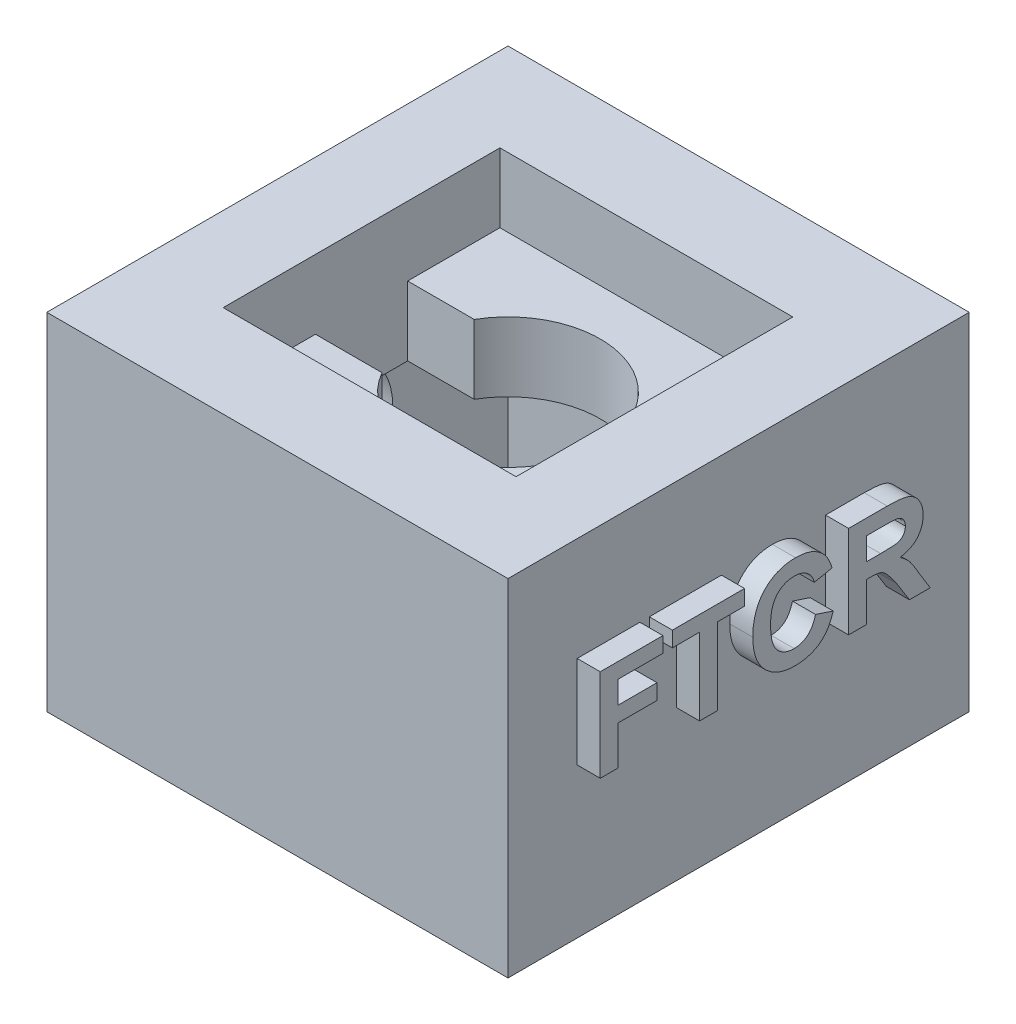
from build123d import *

# Parameters (mm, degrees)
SKETCH6_W           = 20
SKETCH6_H           = 20
BOSS_EXTRUDE3_DEPTH = 15
SKETCH7_W           = 12.7
SKETCH7_H           = 12
CUT_EXTRUDE2_DEPTH  = 3
SKETCH8_W           = 16
SKETCH8_H           = 16
CUT_EXTRUDE3_DEPTH  = 9
SKETCH9_R           = 4
CUT_EXTRUDE4_DEPTH  = 13
SKETCH10_W          = 12.7
SKETCH10_H          = 4
CUT_EXTRUDE5_DEPTH  = 13
SKETCH11_R          = 3
CUT_EXTRUDE6_DEPTH  = 3
BOSS_EXTRUDE4_DEPTH = 1


with BuildPart() as part:
    # Sketch6 → Boss-Extrude3 (new body)
    with BuildSketch(Plane(origin=(0, 0, 0), x_dir=(1, 0, 0), z_dir=(0, 1, 0))):
        Rectangle(SKETCH6_W, SKETCH6_H)
    extrude(amount=BOSS_EXTRUDE3_DEPTH)

    # Sketch7 → Cut-Extrude2 (cut)
    with BuildSketch(Plane(origin=(0, 15, 0), x_dir=(1, 0, 0), z_dir=(0, 1, 0))):
        Rectangle(SKETCH7_W, SKETCH7_H)
    extrude(amount=-CUT_EXTRUDE2_DEPTH, mode=Mode.SUBTRACT)

    # Sketch8 → Cut-Extrude3 (cut)
    with BuildSketch(Plane.XZ):
        Rectangle(SKETCH8_W, SKETCH8_H)
    extrude(amount=-CUT_EXTRUDE3_DEPTH, mode=Mode.SUBTRACT)

    # Sketch9 → Cut-Extrude4 (cut, through all)
    with BuildSketch(Plane(origin=(0, 12, 0), x_dir=(1, 0, 0), z_dir=(0, 1, 0))):
        Circle(SKETCH9_R)
    extrude(amount=-CUT_EXTRUDE4_DEPTH, mode=Mode.SUBTRACT)

    # Sketch10 → Cut-Extrude5 (cut, through all)
    with BuildSketch(Plane(origin=(0, 12, 0), x_dir=(1, 0, 0), z_dir=(0, 1, 0))):
        Rectangle(SKETCH10_W, SKETCH10_H)
    extrude(amount=-CUT_EXTRUDE5_DEPTH, mode=Mode.SUBTRACT)

    # Sketch11 → Cut-Extrude6 (cut, through all)
    with BuildSketch(Plane(origin=(-8, 0, 0), x_dir=(0, 0, -1), z_dir=(1, 0, 0))):
        with Locations((0, 6)):
            Circle(SKETCH11_R)
    extrude(amount=-CUT_EXTRUDE6_DEPTH, mode=Mode.SUBTRACT)

    # Sketch12 → Boss-Extrude4 (add)
    with BuildSketch(Plane(origin=(10, 0, 0), x_dir=(0, 0, -1), z_dir=(1, 0, 0))):
        Polygon((-7, 6.5), (-7, 10.5), (-4.282051282, 10.5), (-4.282051282, 9.833333333), (-6.230769231, 9.833333333), (-6.230769231, 8.858974359), (-4.538461538, 8.858974359), (-4.538461538, 8.192307692), (-6.230769231, 8.192307692), (-6.230769231, 6.5), align=None)
        Polygon((-2.692307692, 6.5), (-2.692307692, 9.833333333), (-3.871794872, 9.833333333), (-3.871794872, 10.5), (-0.743589744, 10.5), (-0.743589744, 9.833333333), (-1.923076923, 9.833333333), (-1.923076923, 6.5), align=None)
        with BuildLine():
            Line((2.333333333, 7.987179487), (3.102564103, 7.730769231))
            add(Edge.make_bspline(
                [(3.102564103, 7.730769231), (3.086930966, 7.680332707), (3.056316366, 7.581562127), (3.000102828, 7.440000434), (2.93582352, 7.308808759), (2.865790067, 7.18645159), (2.785647227, 7.076089811), (2.699881822, 6.974069408), (2.605943704, 6.882539125), (2.50429639, 6.801303513), (2.395918291, 6.729465094), (2.279550482, 6.668733578), (2.156929586, 6.616427097), (2.026812158, 6.574047819), (1.890061746, 6.540108451), (1.746036707, 6.517691314), (1.595410776, 6.502491754), (1.492561226, 6.500843752), (1.439903846, 6.5)],
                knots=[0, 0, 0, 0, 0.000158372, 0.000310143, 0.000456354, 0.000596395, 0.000732484, 0.000864938, 0.000995832, 0.001125226, 0.001254791, 0.00138526, 0.00151846, 0.001654277, 0.001795369, 0.001940668, 0.002091201, 0.002249127, 0.002249127, 0.002249127, 0.002249127], degree=3))
            add(Edge.make_bspline(
                [(1.439903846, 6.5), (1.37490907, 6.501343951), (1.247062403, 6.503987543), (1.060098762, 6.530598944), (0.881930865, 6.572119076), (0.712303833, 6.629602977), (0.552349902, 6.705740257), (0.400609747, 6.797399672), (0.258187679, 6.906442057), (0.125583338, 7.031029627), (0.005109088, 7.170211291), (-0.099069972, 7.323234951), (-0.188087376, 7.487944876), (-0.260035831, 7.665126422), (-0.316294668, 7.854597653), (-0.355704101, 8.056096597), (-0.380364017, 8.269686724), (-0.383173502, 8.416062825), (-0.384615385, 8.491185897)],
                knots=[0, 0, 0, 0, 0.000194876, 0.000383328, 0.000565247, 0.000743131, 0.000919481, 0.001095654, 0.001274025, 0.001456555, 0.001640634, 0.001825103, 0.002010814, 0.002201277, 0.002397754, 0.002602828, 0.002816524, 0.003041826, 0.003041826, 0.003041826, 0.003041826], degree=3))
            add(Edge.make_bspline(
                [(-0.384615385, 8.491185897), (-0.383180001, 8.570314328), (-0.38037983, 8.724679457), (-0.355673717, 8.94911314), (-0.317318946, 9.160628802), (-0.260965024, 9.357914963), (-0.190073862, 9.542360053), (-0.100948381, 9.712133102), (0.002191496, 9.869497646), (0.122118975, 10.011569389), (0.255327645, 10.137709886), (0.39807721, 10.249252186), (0.551699395, 10.342828179), (0.715353547, 10.419349729), (0.889259153, 10.478565871), (1.073074015, 10.521206141), (1.266948526, 10.54602552), (1.399501491, 10.549505903), (1.467147436, 10.551282051)],
                knots=[0, 0, 0, 0, 0.000237315, 0.000462958, 0.000676534, 0.000881474, 0.001077592, 0.001268258, 0.001455604, 0.001640993, 0.001824625, 0.002005097, 0.002183471, 0.002363062, 0.002546015, 0.002733578, 0.002928278, 0.003131194, 0.003131194, 0.003131194, 0.003131194], degree=3))
            add(Edge.make_bspline(
                [(1.467147436, 10.551282051), (1.526225253, 10.549793443), (1.642055176, 10.54687483), (1.811676336, 10.527045661), (1.972429727, 10.492246794), (2.125184274, 10.445276061), (2.269070412, 10.383287189), (2.404345914, 10.307537426), (2.531475755, 10.218427566), (2.608074101, 10.148822211), (2.646634615, 10.113782051)],
                knots=[0, 0, 0, 0, 0.00017723, 0.000347483, 0.000511402, 0.000670052, 0.000826188, 0.000980443, 0.00113451, 0.001290694, 0.001290694, 0.001290694, 0.001290694], degree=3))
            add(Edge.make_bspline(
                [(2.646634615, 10.113782051), (2.668983783, 10.091485642), (2.714207085, 10.046369096), (2.774592886, 9.970199583), (2.831846127, 9.88820309), (2.885058086, 9.79898086), (2.932546964, 9.701858642), (2.976597971, 9.598327922), (3.017154081, 9.487989626), (3.039707942, 9.411200989), (3.051282051, 9.371794872)],
                knots=[0, 0, 0, 0, 9.4636e-05, 0.000191495, 0.000291077, 0.000394554, 0.000502775, 0.000615143, 0.000732001, 0.000855185, 0.000855185, 0.000855185, 0.000855185], degree=3))
            Line((3.051282051, 9.371794872), (2.282051282, 9.217948718))
            add(Edge.make_bspline(
                [(2.282051282, 9.217948718), (2.275513137, 9.243179532), (2.262634706, 9.292877615), (2.236576953, 9.364291032), (2.206686657, 9.432055987), (2.169640371, 9.494512679), (2.130287637, 9.554439631), (2.083696219, 9.6091759), (2.032841611, 9.660156003), (1.977357464, 9.706850892), (1.917905228, 9.748317024), (1.855629569, 9.785592493), (1.789398602, 9.816020924), (1.720093361, 9.840637453), (1.647989885, 9.861276558), (1.57244623, 9.874026295), (1.494111228, 9.883813973), (1.440738816, 9.884344332), (1.413461538, 9.884615385)],
                knots=[0, 0, 0, 0, 7.8149e-05, 0.000153932, 0.000227807, 0.000299962, 0.000371524, 0.000442621, 0.000515145, 0.000587372, 0.000659842, 0.000732401, 0.000804819, 0.000878069, 0.000952915, 0.001029458, 0.00110768, 0.001189446, 0.001189446, 0.001189446, 0.001189446], degree=3))
            add(Edge.make_bspline(
                [(1.413461538, 9.884615385), (1.376001256, 9.883858858), (1.302889995, 9.882382343), (1.196026684, 9.865920209), (1.094173803, 9.842945596), (0.997742119, 9.807863482), (0.907328808, 9.762993748), (0.821906318, 9.70844957), (0.741943493, 9.644464572), (0.667413306, 9.570280743), (0.600532593, 9.484556804), (0.5417349, 9.387115764), (0.492956944, 9.276851355), (0.453357, 9.154845615), (0.422187333, 9.020808414), (0.399929736, 8.874567842), (0.387620617, 8.716023857), (0.385638745, 8.606324103), (0.384615385, 8.549679487)],
                knots=[0, 0, 0, 0, 0.000112282, 0.000219142, 0.000323705, 0.000425092, 0.000526146, 0.00062595, 0.000728564, 0.000832817, 0.000940693, 0.001053926, 0.00117336, 0.001301575, 0.00143821, 0.001585759, 0.00174493, 0.001914869, 0.001914869, 0.001914869, 0.001914869], degree=3))
            add(Edge.make_bspline(
                [(0.384615385, 8.549679487), (0.385628668, 8.48956389), (0.387581109, 8.373730394), (0.399887617, 8.206651289), (0.422287541, 8.052982713), (0.453042964, 7.912451958), (0.492842466, 7.785145101), (0.541537934, 7.671282443), (0.599427553, 7.57073064), (0.666421258, 7.483556646), (0.740825334, 7.408674453), (0.820624603, 7.344292817), (0.905348265, 7.289246772), (0.995506149, 7.243958435), (1.091441168, 7.209698313), (1.192364876, 7.184852271), (1.298647581, 7.169057247), (1.371471162, 7.167474695), (1.408653846, 7.166666667)],
                knots=[0, 0, 0, 0, 0.000180353, 0.000347512, 0.000502192, 0.000645857, 0.000778647, 0.000901748, 0.001016642, 0.001125784, 0.001230605, 0.001332594, 0.001432832, 0.001533168, 0.001634555, 0.001737749, 0.001844608, 0.00195609, 0.00195609, 0.00195609, 0.00195609], degree=3))
            add(Edge.make_bspline(
                [(1.408653846, 7.166666667), (1.436182549, 7.167353464), (1.490313655, 7.16870395), (1.570323604, 7.177275378), (1.647116838, 7.193632714), (1.721069235, 7.21526233), (1.792468123, 7.242401116), (1.860224437, 7.277214723), (1.925671252, 7.317227793), (1.987450599, 7.364120046), (2.046389734, 7.416765552), (2.100145723, 7.477610637), (2.150008865, 7.54519333), (2.195346572, 7.619965289), (2.23767372, 7.701286492), (2.273685874, 7.790423966), (2.307234422, 7.88593721), (2.324481746, 7.95284262), (2.333333333, 7.987179487)],
                knots=[0, 0, 0, 0, 8.2594e-05, 0.000162409, 0.000240984, 0.000317811, 0.000393404, 0.000469732, 0.000546005, 0.000623249, 0.000702105, 0.000782689, 0.000866345, 0.000953747, 0.001044773, 0.001141051, 0.001241904, 0.001348233, 0.001348233, 0.001348233, 0.001348233], degree=3))
        make_face()
        with BuildLine():
            Line((3.769230769, 6.5), (3.769230769, 10.5))
            Line((3.769230769, 10.5), (5.447916667, 10.5))
            add(Edge.make_bspline(
                [(5.447916667, 10.5), (5.49893359, 10.499685584), (5.597252539, 10.499079646), (5.739440921, 10.494661029), (5.870570526, 10.48540377), (5.991223047, 10.474919847), (6.10081898, 10.459666415), (6.199791649, 10.441392954), (6.287974425, 10.420216531), (6.366653948, 10.394854332), (6.438393689, 10.365826413), (6.505222778, 10.331275023), (6.56787602, 10.290793823), (6.627315708, 10.245778088), (6.683793544, 10.196158651), (6.735761206, 10.140622336), (6.784124108, 10.079996096), (6.828843229, 10.014784345), (6.868237975, 9.945275033), (6.904234431, 9.873700467), (6.933536903, 9.799298985), (6.957740478, 9.722421075), (6.977074668, 9.643233648), (6.990494229, 9.561535382), (6.998871917, 9.477474151), (6.999619794, 9.420693228), (7, 9.391826923)],
                knots=[0, 0, 0, 0, 0.000153053, 0.000294962, 0.000426667, 0.000547382, 0.000658208, 0.000758474, 0.000849231, 0.000930066, 0.001006251, 0.001081152, 0.001155391, 0.001229751, 0.001304678, 0.001380635, 0.001457596, 0.001537161, 0.001617565, 0.001697119, 0.001777319, 0.001857146, 0.001938771, 0.002021629, 0.002105347, 0.002191918, 0.002191918, 0.002191918, 0.002191918], degree=3))
            add(Edge.make_bspline(
                [(7, 9.391826923), (6.999294775, 9.355463459), (6.99791657, 9.284399226), (6.985233604, 9.180241178), (6.966396159, 9.080725598), (6.939543527, 8.985714616), (6.902621704, 8.896325697), (6.859759981, 8.811306629), (6.808640176, 8.7309458), (6.749609592, 8.656039863), (6.682721077, 8.586522511), (6.607681499, 8.523824359), (6.525026618, 8.467700367), (6.434256422, 8.41847418), (6.336002949, 8.376391124), (6.229840139, 8.340983723), (6.116248592, 8.312166044), (6.037234374, 8.298606464), (5.996794872, 8.291666667)],
                knots=[0, 0, 0, 0, 0.000109048, 0.00021311, 0.000314313, 0.000412711, 0.000508684, 0.000604006, 0.000698033, 0.000793893, 0.000889662, 0.000986921, 0.001086709, 0.0011889, 0.001296218, 0.001406949, 0.00152433, 0.001647386, 0.001647386, 0.001647386, 0.001647386], degree=3))
            add(Edge.make_bspline(
                [(5.996794872, 8.291666667), (6.035904412, 8.26576405), (6.112447112, 8.2150691), (6.218349446, 8.131573883), (6.313424615, 8.043939195), (6.385410736, 7.966008978), (6.440724652, 7.897477725), (6.485261805, 7.837539629), (6.533302265, 7.768559576), (6.584374858, 7.69050019), (6.639989421, 7.60405211), (6.698077548, 7.507892117), (6.759854815, 7.40295817), (6.801390235, 7.329656495), (6.822916667, 7.291666667)],
                knots=[0, 0, 0, 0, 0.000140684, 0.000275337, 0.000404055, 0.000528243, 0.000593191, 0.000668192, 0.000752216, 0.000845333, 0.000948026, 0.001060574, 0.001182332, 0.001313324, 0.001313324, 0.001313324, 0.001313324], degree=3))
            Line((6.822916667, 7.291666667), (7.307692308, 6.5))
            Line((7.307692308, 6.5), (6.408653846, 6.5))
            Line((6.408653846, 6.5), (5.83974359, 7.407852564))
            add(Edge.make_bspline(
                [(5.83974359, 7.407852564), (5.813615839, 7.444211404), (5.763732592, 7.513627904), (5.691723042, 7.612271004), (5.625840695, 7.700081081), (5.5678389, 7.778330011), (5.51478279, 7.844799254), (5.468283361, 7.900647139), (5.429287744, 7.947072081), (5.385164107, 7.993104413), (5.33383094, 8.04041283), (5.27028458, 8.086281032), (5.205028363, 8.122846679), (5.13511154, 8.150747127), (5.054254846, 8.170201173), (4.957052295, 8.182595873), (4.840447611, 8.191740544), (4.756165786, 8.192109059), (4.710737179, 8.192307692)],
                knots=[0, 0, 0, 0, 0.000134319, 0.000256443, 0.00036638, 0.000463655, 0.000548625, 0.000621467, 0.000681697, 0.000730437, 0.000812688, 0.000890746, 0.000964994, 0.001036564, 0.001115854, 0.001213762, 0.001330282, 0.001466521, 0.001466521, 0.001466521, 0.001466521], degree=3))
            Line((4.710737179, 8.192307692), (4.538461538, 8.192307692))
            Line((4.538461538, 8.192307692), (4.538461538, 6.5))
            Line((4.538461538, 6.5), (3.769230769, 6.5))
        make_face()
        with BuildLine():
            Line((4.538461538, 8.858974359), (5.157852564, 8.858974359))
            add(Edge.make_bspline(
                [(5.157852564, 8.858974359), (5.205664702, 8.859076823), (5.296754903, 8.859272035), (5.426286981, 8.8620996), (5.542002743, 8.864499518), (5.643209718, 8.870529414), (5.730360713, 8.876505609), (5.803106122, 8.884272494), (5.862058845, 8.893452701), (5.920942707, 8.907725514), (5.981259789, 8.932593072), (6.045546386, 8.968011795), (6.100490549, 9.013959484), (6.148084885, 9.067079658), (6.184392696, 9.129527255), (6.212830299, 9.198520162), (6.227248766, 9.275591464), (6.229571155, 9.329011913), (6.230769231, 9.356570513)],
                knots=[0, 0, 0, 0, 0.000143432, 0.000273262, 0.000388691, 0.000490608, 0.000577384, 0.000650739, 0.000710018, 0.000756271, 0.000832156, 0.000905007, 0.000975592, 0.001045996, 0.001117866, 0.001191221, 0.001268851, 0.001351573, 0.001351573, 0.001351573, 0.001351573], degree=3))
            add(Edge.make_bspline(
                [(6.230769231, 9.356570513), (6.229406644, 9.387400505), (6.226777754, 9.446882003), (6.206045947, 9.531524741), (6.169859423, 9.606294947), (6.120161591, 9.671316068), (6.057773791, 9.72622084), (5.983463024, 9.769803278), (5.897781364, 9.80226167), (5.835982217, 9.814248491), (5.803685897, 9.820512821)],
                knots=[0, 0, 0, 0, 9.2429e-05, 0.000178327, 0.00025932, 0.000339932, 0.000422246, 0.000507034, 0.000597067, 0.000695625, 0.000695625, 0.000695625, 0.000695625], degree=3))
            add(Edge.make_bspline(
                [(5.803685897, 9.820512821), (5.793010316, 9.821685838), (5.767706947, 9.824466134), (5.723024197, 9.826251796), (5.665891568, 9.828996554), (5.595617528, 9.830118275), (5.5128299, 9.832084553), (5.417199484, 9.832445612), (5.309030106, 9.833599168), (5.232639352, 9.833425188), (5.192307692, 9.833333333)],
                knots=[0, 0, 0, 0, 3.2211e-05, 7.6347e-05, 0.00013409, 0.000203819, 0.000287168, 0.000382524, 0.0004907, 0.000611694, 0.000611694, 0.000611694, 0.000611694], degree=3))
            Line((5.192307692, 9.833333333), (4.538461538, 9.833333333))
            Line((4.538461538, 9.833333333), (4.538461538, 8.858974359))
        make_face(mode=Mode.SUBTRACT)
    extrude(amount=BOSS_EXTRUDE4_DEPTH)


solid = part.part
